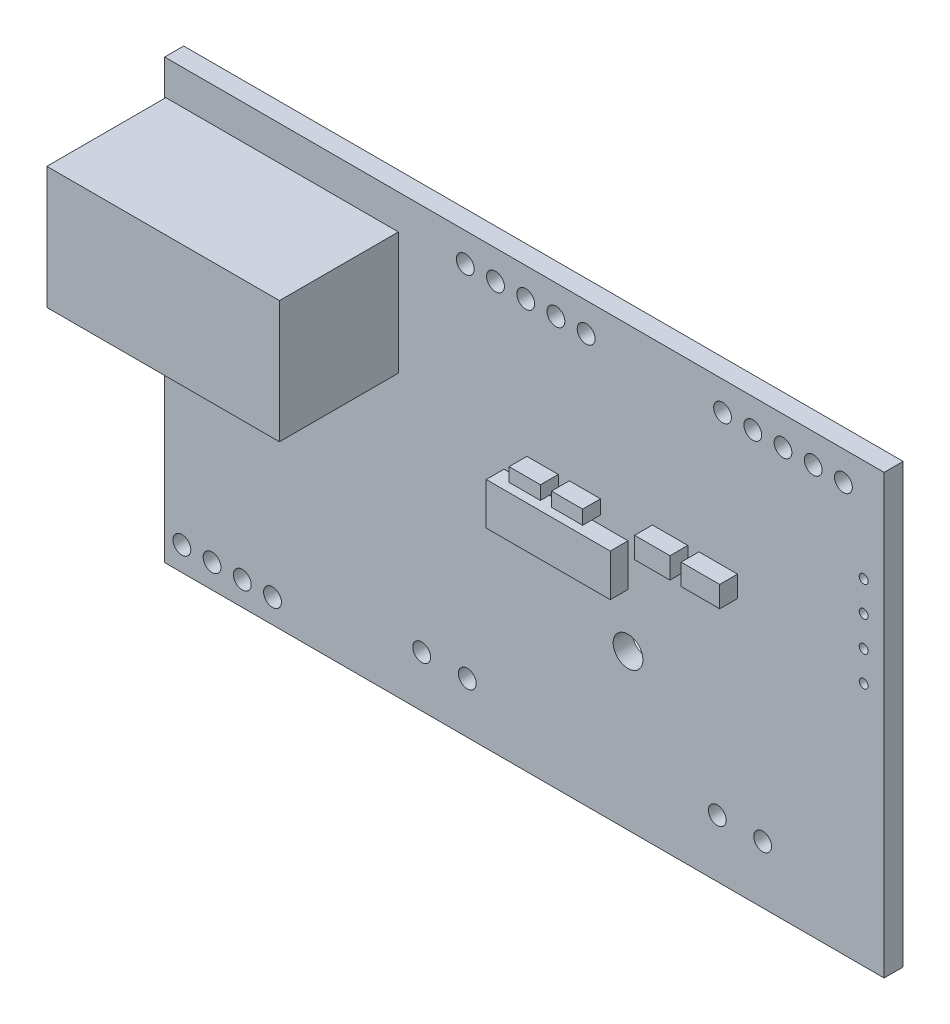
from build123d import *

# Parameters (mm, degrees)
ESQUISSE1_W             = 60.48
ESQUISSE1_H             = 36.81
BOSS_EXTRU_1_DEPTH      = 1.6
HOLES_R                 = 0.746107215
HOLES_R_2               = 0.75
HOLES_R_3               = 1.250449685
HOLES_R_4               = 0.749278137
ENL_V_MAT_EXTRU_1_DEPTH = 1.6
ESQUISSE4_R             = 0.375
ENL_V_MAT_EXTRU_2_DEPTH = 1.6
COMPOSANTS_W            = 10.427845653
COMPOSANTS_H            = 3.536930105
COMPOSANTS_W_2          = 3.243777278
COMPOSANTS_H_2          = 1.776354224
COMPOSANTS_W_3          = 2.973462505
COMPOSANTS_W_4          = 2.623427815
COMPOSANTS_H_3          = 1.178088166
COMPOSANTS_W_5          = 2.634336038
COMPOSANTS_H_4          = 1.145363495
BOSS_EXTRU_2_DEPTH      = 1.5
ESQUISSE6_W             = 19.651518654
ESQUISSE6_H             = 10.276618936
BOSS_EXTRU_3_DEPTH      = 10
ESQUISSE7_W             = 10
ESQUISSE7_H             = 10.276618936
ENL_V_MAT_EXTRU_3_DEPTH = 0.1


with BuildPart() as part:
    # Esquisse1 → Boss.-Extru.1 (new body)
    with BuildSketch(Plane.XY):
        Rectangle(ESQUISSE1_W, ESQUISSE1_H)
    extrude(amount=BOSS_EXTRU_1_DEPTH)

    # holes → Enlèv. mat.-Extru.1 (cut)
    with BuildSketch(Plane(origin=(0, 0, 0), x_dir=(-1, 0, 0), z_dir=(0, 0, -1))):
        with Locations((-26.820081416, 15.971189451)):
            Circle(HOLES_R)
        with Locations((-24.280081416, 15.971189451)):
            Circle(HOLES_R)
        with Locations((-21.740081416, 15.971189451)):
            Circle(HOLES_R)
        with Locations((-19.200081416, 15.971189451)):
            Circle(HOLES_R)
        with Locations((-16.660081416, 15.971189451)):
            Circle(HOLES_R)
        with Locations((-0.111966665, 15.971189451)):
            Circle(HOLES_R_2)
        with Locations((2.428033335, 15.971189451)):
            Circle(HOLES_R_2)
        with Locations((4.968033335, 15.971189451)):
            Circle(HOLES_R_2)
        with Locations((-2.651966665, 15.971189451)):
            Circle(HOLES_R_2)
        with Locations((-5.191966665, 15.971189451)):
            Circle(HOLES_R_2)
        with Locations((-8.714200976, -5.38768812)):
            Circle(HOLES_R_3)
        with Locations((23.712324903, -16.38246564)):
            Circle(HOLES_R_2)
        with Locations((26.252324903, -16.38246564)):
            Circle(HOLES_R_2)
        with Locations((28.792324903, -16.38246564)):
            Circle(HOLES_R_2)
        with Locations((21.172324903, -16.38246564)):
            Circle(HOLES_R_2)
        with Locations((-16.219684892, -13.565590628)):
            Circle(HOLES_R_2)
        with Locations((-20.031169083, -13.565590628)):
            Circle(HOLES_R_2)
        with Locations((4.79677487, -14.121575923)):
            Circle(HOLES_R_2)
        with Locations((8.63305215, -14.121575923)):
            Circle(HOLES_R_4)
    extrude(amount=-ENL_V_MAT_EXTRU_1_DEPTH, mode=Mode.SUBTRACT)

    # Esquisse4 → Enlèv. mat.-Extru.2 (cut)
    with BuildSketch(Plane.XY.offset(1.6)):
        with Locations((28.522800068, 2.172855337)):
            Circle(ESQUISSE4_R)
        with Locations((28.522800068, 4.712855337)):
            Circle(ESQUISSE4_R)
        with Locations((28.522800068, 7.252855337)):
            Circle(ESQUISSE4_R)
        with Locations((28.522800068, 9.792855337)):
            Circle(ESQUISSE4_R)
    extrude(amount=-ENL_V_MAT_EXTRU_2_DEPTH, mode=Mode.SUBTRACT)

    # composants → Boss.-Extru.2 (add)
    with BuildSketch(Plane.XY.offset(1.6)):
        with Locations((3.505618489, 0.895242457)):
            Rectangle(COMPOSANTS_W, COMPOSANTS_H)
        with Locations((16.297230516, 3.949212585)):
            Rectangle(COMPOSANTS_W_2, COMPOSANTS_H_2)
        with Locations((12.252163018, 3.949212585)):
            Rectangle(COMPOSANTS_W_3, COMPOSANTS_H_2)
        with Locations((5.088820687, 3.970981166)):
            Rectangle(COMPOSANTS_W_4, COMPOSANTS_H_3)
        with Locations((1.532739741, 3.987343502)):
            Rectangle(COMPOSANTS_W_5, COMPOSANTS_H_4)
    extrude(amount=BOSS_EXTRU_2_DEPTH)

    # Esquisse6 → Boss.-Extru.3 (add)
    with BuildSketch(Plane.XY.offset(1.6)):
        with Locations((-20.414240673, 10.357703845)):
            Rectangle(ESQUISSE6_W, ESQUISSE6_H)
    extrude(amount=BOSS_EXTRU_3_DEPTH)

    # Esquisse7 → Enlèv. mat.-Extru.3 (cut)
    with BuildSketch(Plane.ZY.offset(30.24)):
        with Locations((6.6, 10.357703845)):
            Rectangle(ESQUISSE7_W, ESQUISSE7_H)
    extrude(amount=-ENL_V_MAT_EXTRU_3_DEPTH, mode=Mode.SUBTRACT)


solid = part.part
